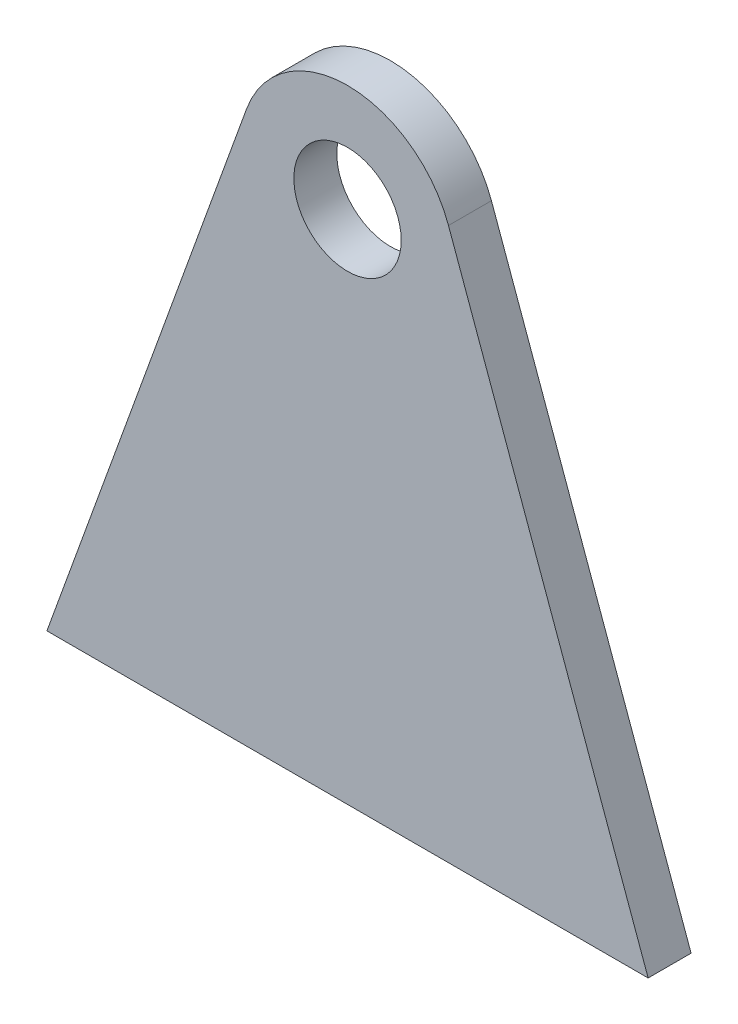
from build123d import *

# Parameters (mm, degrees)
SKETCH1_R           = 25
BOSS_EXTRUDE1_DEPTH = 10


with BuildPart() as part:
    # Sketch1 → Boss-Extrude1 (new body, symmetric)
    with BuildSketch(Plane.XY):
        with BuildLine():
            Line((-140, -240), (140, -240))
            Line((140, -240), (47.017565913, 17.010246783))
            ThreePointArc((47.017565913, 17.010246783), (0, 50), (-47.017565913, 17.010246783))
            Line((-47.017565913, 17.010246783), (-140, -240))
        make_face()
        Circle(SKETCH1_R, mode=Mode.SUBTRACT)
    extrude(amount=BOSS_EXTRUDE1_DEPTH, both=True)


solid = part.part
